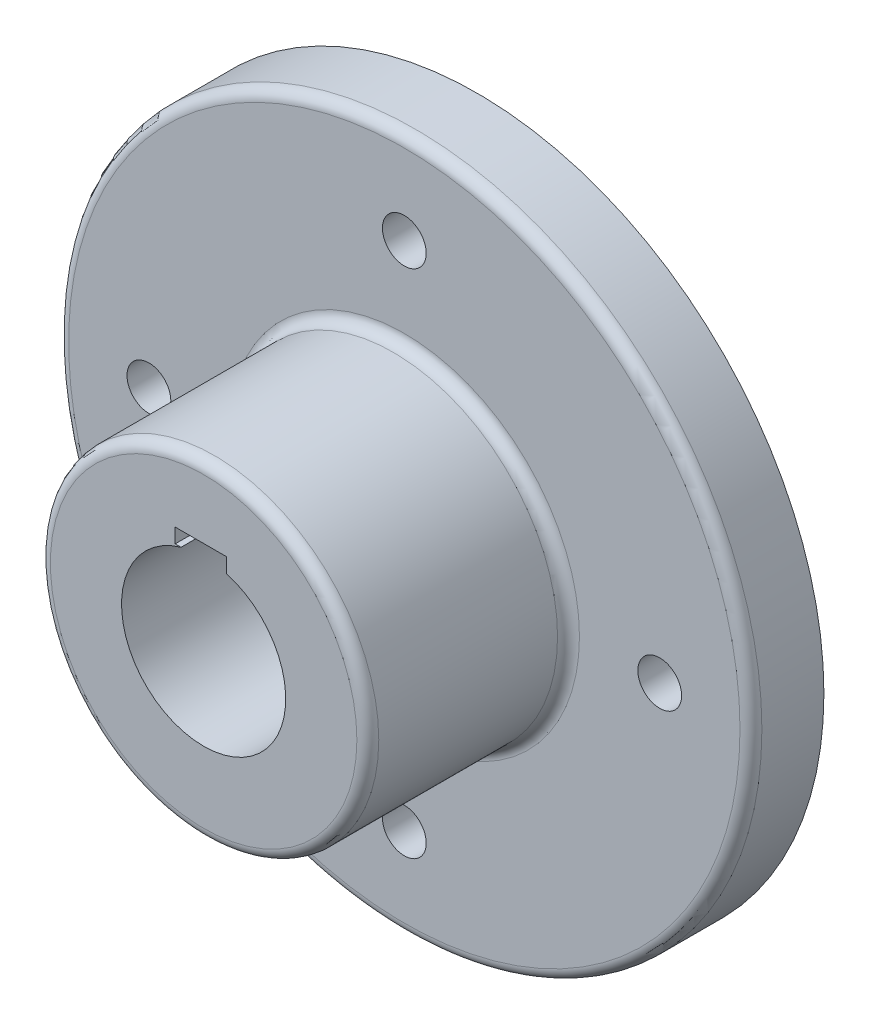
from build123d import *

# Parameters (mm, degrees)
SKETCH2_R           = 95
BOSS_EXTRUDE1_DEPTH = 20
SKETCH3_R           = 45
BOSS_EXTRUDE2_DEPTH = 55
SKETCH4_R           = 22.5
CUT_EXTRUDE1_DEPTH  = 75
SKETCH5_R           = 6
CUT_EXTRUDE2_DEPTH  = 20
SKETCH6_W           = 14
SKETCH6_H           = 4
CUT_EXTRUDE3_DEPTH  = 75
FILLET1_R           = 3


with BuildPart() as part:
    # Sketch2 → Boss-Extrude1 (new body)
    with BuildSketch(Plane.XY):
        Circle(SKETCH2_R)
    extrude(amount=BOSS_EXTRUDE1_DEPTH)

    # Sketch3 → Boss-Extrude2 (add)
    with BuildSketch(Plane.XY.offset(20)):
        Circle(SKETCH3_R)
    extrude(amount=BOSS_EXTRUDE2_DEPTH)

    # Sketch4 → Cut-Extrude1 (cut)
    with BuildSketch(Plane(origin=(0, 0, 0), x_dir=(-1, 0, 0), z_dir=(0, 0, -1))):
        Circle(SKETCH4_R)
    extrude(amount=-CUT_EXTRUDE1_DEPTH, mode=Mode.SUBTRACT)

    # Sketch5 → Cut-Extrude2 (cut)
    with BuildSketch(Plane(origin=(0, 0, 0), x_dir=(-1, 0, 0), z_dir=(0, 0, -1))):
        with Locations((0, 70)):
            Circle(SKETCH5_R)
        with Locations((70, 0)):
            Circle(SKETCH5_R)
        with Locations((0, -70)):
            Circle(SKETCH5_R)
        with Locations((-70, 0)):
            Circle(SKETCH5_R)
    extrude(amount=-CUT_EXTRUDE2_DEPTH, mode=Mode.SUBTRACT)

    # Sketch6 → Cut-Extrude3 (cut)
    with BuildSketch(Plane(origin=(0, 0, 0), x_dir=(-1, 0, 0), z_dir=(0, 0, -1))):
        with Locations((0.80166167, 23.629392085)):
            Rectangle(SKETCH6_W, SKETCH6_H)
    extrude(amount=-CUT_EXTRUDE3_DEPTH, mode=Mode.SUBTRACT)

    # Fillet1
    fillet1_edges = [part.edges().sort_by_distance(p)[0] for p in [
        (-95, 0, 20),
        (-45, 0, 20),
        (-45, 0, 75),
    ]]
    fillet(fillet1_edges, radius=FILLET1_R)


solid = part.part
